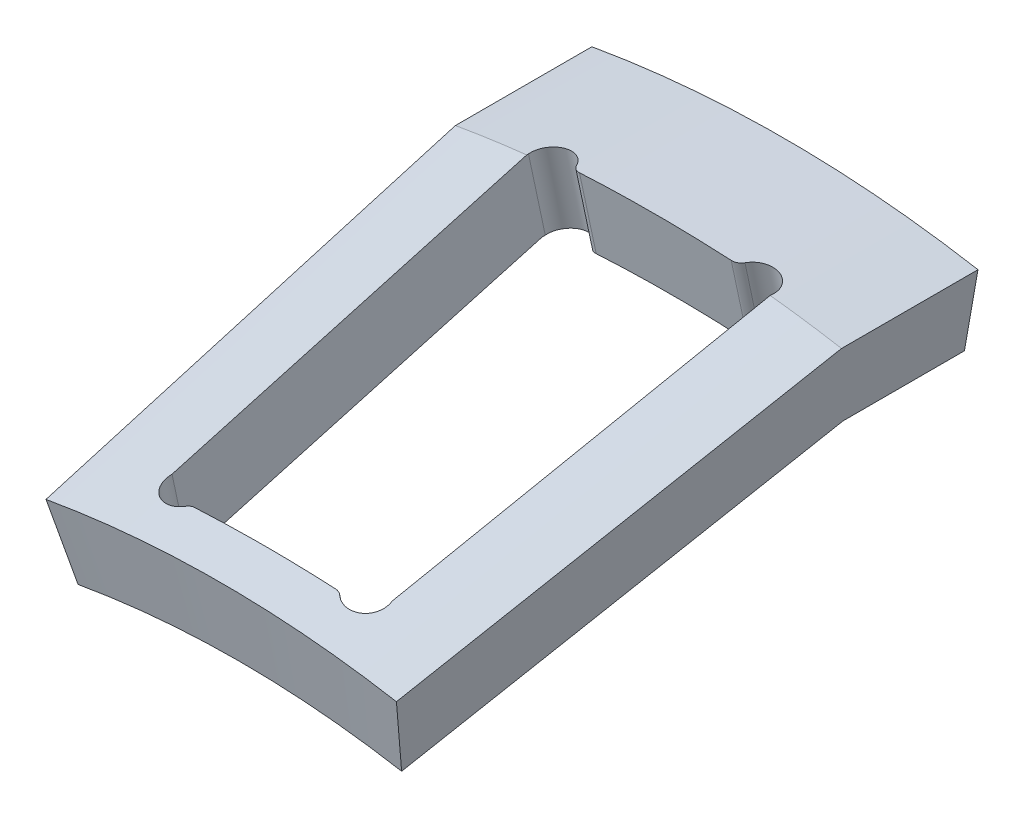
from build123d import *

# Parameters (mm, degrees)
ROTATION1_ANGLE                      = 20
SCHNITT_LINEAR_AUSTRAGEN2_DEPTH      = 15.24
SCHNITT_LINEAR_AUSTRAGEN2_DEPTH_BACK = 2.54


with BuildPart() as part:
    # Skizze1 → Rotation1 (revolve, symmetric)
    with BuildSketch(Plane(origin=(0, 0, 0), x_dir=(0, 0, -1), z_dir=(1, 0, 0))) as rotation1_sk:
        Polygon((0, 161.09315), (68.208324134, 177.5), (90, 177.5), (90, 165), (70.634410551, 165), (2.974994021, 148.725184394), align=None)
    revolve(axis=Axis((0, 0, 0), (0, 0, -1)), revolution_arc=ROTATION1_ANGLE / 2)
    revolve(rotation1_sk.sketch, axis=Axis((0, 0, 0), (0, 0, 1)), revolution_arc=ROTATION1_ANGLE / 2)

    # Skizze4 → Schnitt-Linear austragen2 (cut, two sides)
    with BuildSketch(Plane(origin=(0, 169.424608185, -38.218632457), x_dir=(-1, 0, 0), z_dir=(0, -0.978056789, -0.208338468))) as schnitt_linear_austragen2_sk:
        with BuildLine():
            Line((12.109444482, 32.004), (-12.109444482, 32.004))
            ThreePointArc((-12.109444482, 32.004), (-12.895155782, 32.226245034), (-13.448039836, 32.827122995))
            ThreePointArc((-13.448039836, 32.827122995), (-17.173364468, 34.441533799), (-19.440102095, 31.073111855))
            Line((-19.440102095, 31.073111855), (-17.558493636, -29.330115121))
            ThreePointArc((-17.558493636, -29.330115121), (-16.083752787, -32.838011315), (-12.302447063, -32.411486631))
            ThreePointArc((-12.302447063, -32.411486631), (-11.827451319, -32.109587928), (-11.274626778, -32.004))
            Line((-11.274626778, -32.004), (11.274626778, -32.004))
            ThreePointArc((11.274626778, -32.004), (11.827451319, -32.109587928), (12.302447063, -32.411486631))
            ThreePointArc((12.302447063, -32.411486631), (16.083752787, -32.838011315), (17.558493636, -29.330115121))
            Line((17.558493636, -29.330115121), (19.440102095, 31.073111855))
            ThreePointArc((19.440102095, 31.073111855), (17.173364468, 34.441533799), (13.448039836, 32.827122995))
            ThreePointArc((13.448039836, 32.827122995), (12.895155782, 32.226245034), (12.109444482, 32.004))
        make_face()
    extrude(amount=SCHNITT_LINEAR_AUSTRAGEN2_DEPTH, mode=Mode.SUBTRACT)
    extrude(schnitt_linear_austragen2_sk.sketch, amount=-SCHNITT_LINEAR_AUSTRAGEN2_DEPTH_BACK, mode=Mode.SUBTRACT)


solid = part.part
